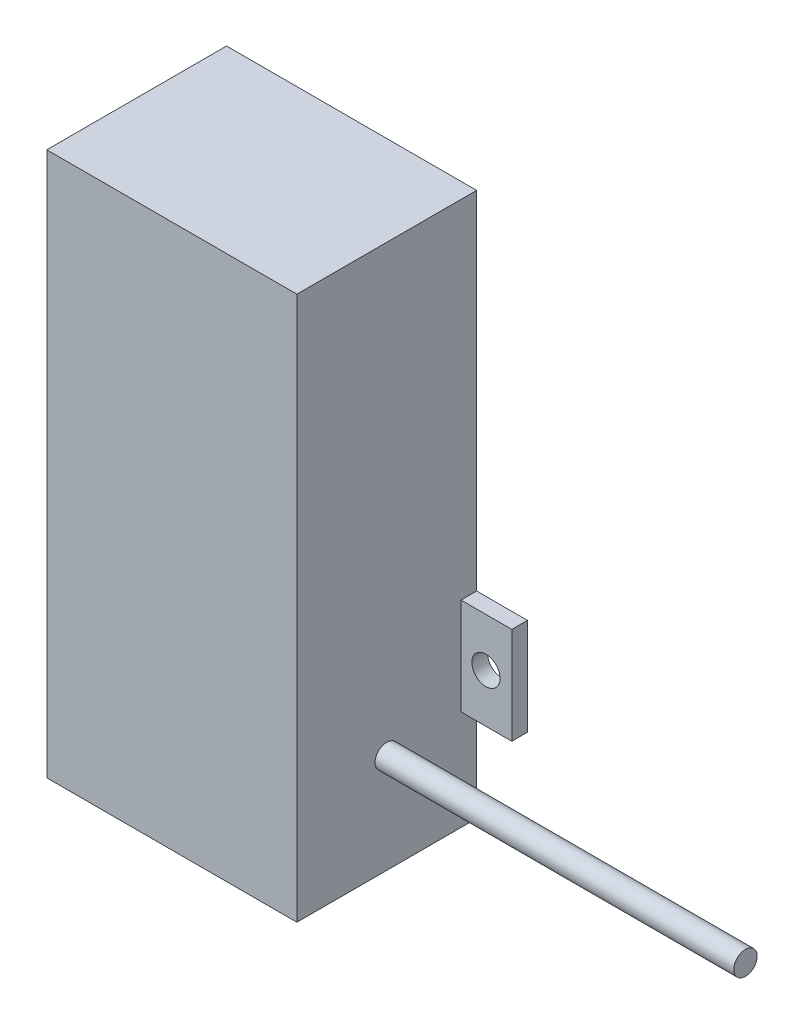
from build123d import *

# Parameters (mm, degrees)
SKETCH_1_W          = 32
SKETCH_1_H          = 69.6
EXTRUDE_1_DEPTH     = 23
SKETCH_2_R          = 1.5
EXTRUDE_2_DEPTH     = 45.9
SKETCH_3_W          = 2
SKETCH_3_H          = 3.6
EXTRUDE_3_DEPTH     = 4.5
SKETCH_5_W          = 16
SKETCH_5_H          = 23
CUT_EXTRUDE_1_DEPTH = 71.5
SKETCH_6_W          = 4.5
SKETCH_6_H          = 3.6
CUT_EXTRUDE_2_DEPTH = 1
SKETCH_7_W          = 2
SKETCH_7_H          = 4.4
EXTRUDE_4_DEPTH     = 6.5
SKETCH_9_W          = 1
SKETCH_9_H          = 1.8
CUT_EXTRUDE_3_DEPTH = 4.5
SKETCH_10_W         = 1.5
SKETCH_10_H         = 2
EXTRUDE_5_DEPTH     = 4.5
SKETCH_12_W         = 2
SKETCH_12_H         = 4.395113111
EXTRUDE_6_DEPTH     = 7.5
SKETCH_15_W         = 2
SKETCH_15_H         = 3.6
EXTRUDE_7_DEPTH     = 6
SKETCH_14_R         = 1.801767182
CUT_EXTRUDE_4_DEPTH = 6
SKETCH_17_W         = 2
SKETCH_17_H         = 4.5
EXTRUDE_8_DEPTH     = 6
SKETCH_16_R         = 1.798109405
CUT_EXTRUDE_5_DEPTH = 6
SKETCH_18_R         = 1.5
CUT_EXTRUDE_6_DEPTH = 45.9


with BuildPart() as part:
    # ｽｹｯﾁ1 → ﾎﾞｽ - 押し出し1 (new body)
    with BuildSketch(Plane.XY):
        with Locations((50.279062003, -5.527058824)):
            Rectangle(SKETCH_1_W, SKETCH_1_H)
    extrude_1 = extrude(amount=EXTRUDE_1_DEPTH)

    # ｽｹｯﾁ2 → ﾎﾞｽ - 押し出し2 (add)
    with BuildSketch(Plane(origin=(66.279062003, 0, 0), x_dir=(0, 0, -1), z_dir=(1, 0, 0))):
        with Locations((-11.5, -27.627058824)):
            Circle(SKETCH_2_R)
    extrude_2 = extrude(amount=EXTRUDE_2_DEPTH)

    # ｽｹｯﾁ3 → ﾎﾞｽ - 押し出し3 (add)
    with BuildSketch(Plane(origin=(66.279062003, 0, 0), x_dir=(0, 0, -1), z_dir=(1, 0, 0))):
        with Locations((-1, -21.322089651)):
            Rectangle(SKETCH_3_W, SKETCH_3_H)
    extrude(amount=EXTRUDE_3_DEPTH)

    # ｽｹｯﾁ5 → ｶｯﾄ - 押し出し1 (cut)
    with BuildSketch(Plane(origin=(0, 29.272941176, 0), x_dir=(1, 0, 0), z_dir=(0, 1, 0))):
        with Locations((42.279062003, -11.5)):
            Rectangle(SKETCH_5_W, SKETCH_5_H)
    extrude(amount=-CUT_EXTRUDE_1_DEPTH, mode=Mode.SUBTRACT)

    # ｽｹｯﾁ6 → ｶｯﾄ - 押し出し2 (cut)
    with BuildSketch(Plane.XY.offset(2)):
        with Locations((68.529062003, -21.322089651)):
            Rectangle(SKETCH_6_W, SKETCH_6_H)
    extrude(amount=-CUT_EXTRUDE_2_DEPTH, mode=Mode.SUBTRACT)

    # ｽｹｯﾁ7 → ﾎﾞｽ - 押し出し4 (add)
    with BuildSketch(Plane(origin=(66.279062003, 0, 0), x_dir=(0, 0, -1), z_dir=(1, 0, 0))):
        with Locations((-1, -17.322089651)):
            Rectangle(SKETCH_7_W, SKETCH_7_H)
    extrude_4 = extrude(amount=EXTRUDE_4_DEPTH)

    # ｽｹｯﾁ9 → ｶｯﾄ - 押し出し3 (cut)
    with BuildSketch(Plane(origin=(70.779062003, 0, 0), x_dir=(0, 0, -1), z_dir=(1, 0, 0))):
        with Locations((-0.5, -22.222089651)):
            Rectangle(SKETCH_9_W, SKETCH_9_H)
    cut_extrude_3 = extrude(amount=-CUT_EXTRUDE_3_DEPTH, mode=Mode.SUBTRACT)

    # ﾐﾗｰ4: ﾎﾞｽ - 押し出し4, ｶｯﾄ - 押し出し3 across plane
    add(extrude_4.mirror(Plane(origin=(66.279062003, -21.322089651, 1), x_dir=(0, 0, 1), z_dir=(0, 1, 0))))
    add(cut_extrude_3.mirror(Plane(origin=(66.279062003, -21.322089651, 1), x_dir=(0, 0, 1), z_dir=(0, 1, 0))), mode=Mode.SUBTRACT)

    # ｽｹｯﾁ10 → ﾎﾞｽ - 押し出し5 (add)
    with BuildSketch(Plane.XZ.offset(19.522089651)):
        with Locations((72.029062003, 1)):
            Rectangle(SKETCH_10_W, SKETCH_10_H)
    extrude_5 = extrude(amount=EXTRUDE_5_DEPTH)

    # ﾐﾗｰ25: ﾎﾞｽ - 押し出し1, ﾎﾞｽ - 押し出し2, ﾎﾞｽ - 押し出し4, ﾎﾞｽ - 押し出し5 across plane
    add(extrude_1.mirror(Plane(origin=(50.279062003, -42.227058824, 0), x_dir=(0, 0, 1), z_dir=(1, 0, 0))))
    add(extrude_2.mirror(Plane(origin=(50.279062003, -42.227058824, 0), x_dir=(0, 0, 1), z_dir=(1, 0, 0))))
    add(extrude_4.mirror(Plane(origin=(50.279062003, -42.227058824, 0), x_dir=(0, 0, 1), z_dir=(1, 0, 0))))
    add(extrude_5.mirror(Plane(origin=(50.279062003, -42.227058824, 0), x_dir=(0, 0, 1), z_dir=(1, 0, 0))))

    # ｽｹｯﾁ12 → ﾎﾞｽ - 押し出し6 (add)
    with BuildSketch(Plane.ZY.offset(-27.779062003)):
        with Locations((1, -26.219646207)):
            Rectangle(SKETCH_12_W, SKETCH_12_H)
    extrude(amount=-EXTRUDE_6_DEPTH)

    # ｽｹｯﾁ15 → ﾎﾞｽ - 押し出し7 (add)
    with BuildSketch(Plane(origin=(66.279062003, 0, 0), x_dir=(0, 0, -1), z_dir=(1, 0, 0))):
        with Locations((-1, -21.322089651)):
            Rectangle(SKETCH_15_W, SKETCH_15_H)
    extrude(amount=EXTRUDE_7_DEPTH)

    # ｽｹｯﾁ14 → ｶｯﾄ - 押し出し4 (cut)
    with BuildSketch(Plane.XY.offset(2)):
        with Locations((69.477294821, -21.322089651)):
            Circle(SKETCH_14_R)
    extrude(amount=-CUT_EXTRUDE_4_DEPTH, mode=Mode.SUBTRACT)

    # ｽｹｯﾁ17 → ﾎﾞｽ - 押し出し8 (add)
    with BuildSketch(Plane.ZY.offset(-34.279062003)):
        with Locations((1, -21.772089651)):
            Rectangle(SKETCH_17_W, SKETCH_17_H)
    extrude(amount=EXTRUDE_8_DEPTH)

    # ｽｹｯﾁ16 → ｶｯﾄ - 押し出し5 (cut)
    with BuildSketch(Plane.XY.offset(2)):
        with Locations((31.077171408, -21.772089651)):
            Circle(SKETCH_16_R)
    extrude(amount=-CUT_EXTRUDE_5_DEPTH, mode=Mode.SUBTRACT)

    # ｽｹｯﾁ18 → ｶｯﾄ - 押し出し6 (cut)
    with BuildSketch(Plane.ZY.offset(11.620937997)):
        with Locations((11.5, -27.627058824)):
            Circle(SKETCH_18_R)
    extrude(amount=-CUT_EXTRUDE_6_DEPTH, mode=Mode.SUBTRACT)


solid = part.part
